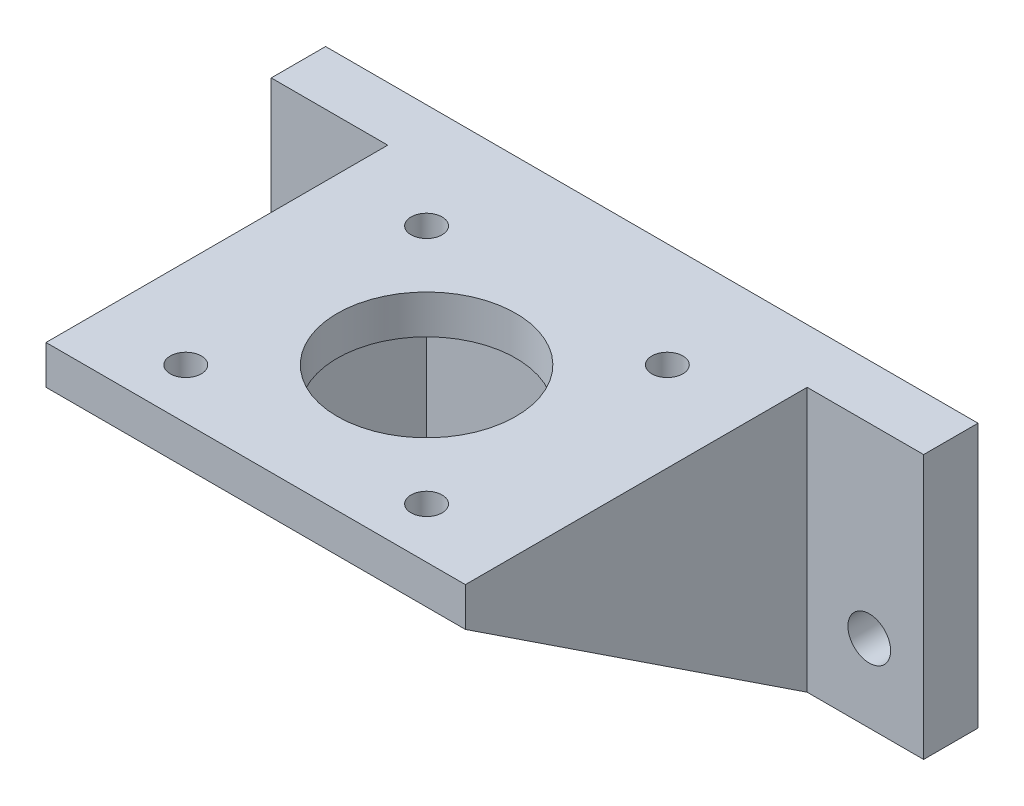
from build123d import *

# Parameters (mm, degrees)
SKETCH2_W           = 44
SKETCH2_H           = 44
SKETCH2_R           = 2
SKETCH2_R_2         = 11.5
BOSS_EXTRUDE1_DEPTH = 5
SKETCH4_W           = 84
SKETCH4_H           = 34
SKETCH4_R           = 2.75
BOSS_EXTRUDE2_DEPTH = 7
BOSS_EXTRUDE3_DEPTH = 5
BOSS_EXTRUDE4_DEPTH = 5


with BuildPart() as part:
    # Sketch2 → Boss-Extrude1 (new body)
    with BuildSketch(Plane(origin=(0, 0, 0), x_dir=(1, 0, 0), z_dir=(0, 1, 0))):
        with Locations((22, 22)):
            Rectangle(SKETCH2_W, SKETCH2_H)
        with Locations((6.5, 37.5)):
            Circle(SKETCH2_R, mode=Mode.SUBTRACT)
        with Locations((6.5, 6.5)):
            Circle(SKETCH2_R, mode=Mode.SUBTRACT)
        with Locations((37.5, 6.5)):
            Circle(SKETCH2_R, mode=Mode.SUBTRACT)
        with Locations((37.5, 37.5)):
            Circle(SKETCH2_R, mode=Mode.SUBTRACT)
        with Locations((22, 22)):
            Circle(SKETCH2_R_2, mode=Mode.SUBTRACT)
    extrude(amount=BOSS_EXTRUDE1_DEPTH)

    # Sketch4 → Boss-Extrude2 (add)
    with BuildSketch(Plane(origin=(0, 0, -44), x_dir=(-1, 0, 0), z_dir=(0, 0, -1))):
        with Locations((-22, -12)):
            Rectangle(SKETCH4_W, SKETCH4_H)
        with Locations((-57, -19)):
            Circle(SKETCH4_R, mode=Mode.SUBTRACT)
        with Locations((13, -19)):
            Circle(SKETCH4_R, mode=Mode.SUBTRACT)
    extrude(amount=BOSS_EXTRUDE2_DEPTH)

    # Sketch5 → Boss-Extrude3 (add)
    with BuildSketch(Plane(origin=(44, 0, 0), x_dir=(0, 0, -1), z_dir=(1, 0, 0))):
        Polygon((0, 5), (51, 5), (51, -29), (44, -29), (0, 0), align=None)
    extrude(amount=BOSS_EXTRUDE3_DEPTH)

    # Sketch6 → Boss-Extrude4 (add)
    with BuildSketch(Plane.ZY):
        Polygon((-51, 5), (0, 5), (0, 0), (-44, -29), (-51, -29), align=None)
    extrude(amount=BOSS_EXTRUDE4_DEPTH)


solid = part.part
